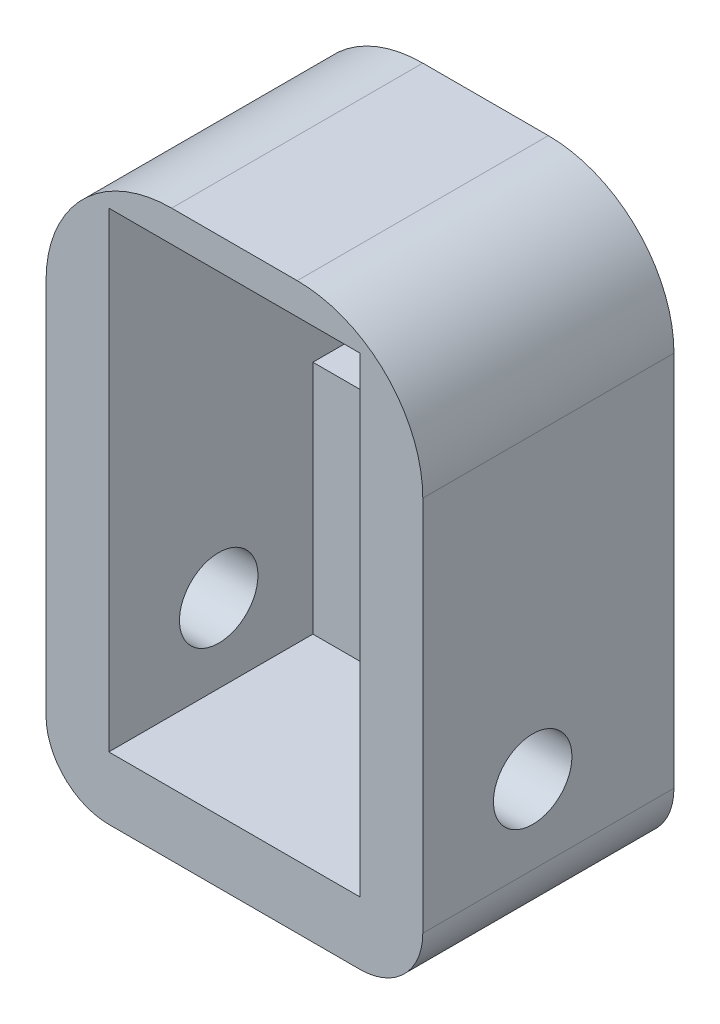
from build123d import *

# Parameters (mm, degrees)
SKETCH_1_W         = 12
SKETCH_1_H         = 18
SKETCH_1_W_2       = 8
SKETCH_1_H_2       = 15
EXTRUDE_1_DEPTH    = 8
SKETCH_1_3_W       = 8
SKETCH_1_3_H       = 7.5
EXTRUDE_2_DEPTH    = 1.5
HOLE_WIZARD_M3_1_D = 2.5
FILLET_2_R         = 4
FILLET_3_R         = 2


with BuildPart() as part:
    # 草图1 → 凸台-拉伸1 (new body)
    with BuildSketch(Plane.XY):
        with Locations((4, 7)):
            Rectangle(SKETCH_1_W, SKETCH_1_H)
        with Locations((4, 7.5)):
            Rectangle(SKETCH_1_W_2, SKETCH_1_H_2, mode=Mode.SUBTRACT)
    extrude(amount=EXTRUDE_1_DEPTH)

    # 草图1<3> → 凸台-拉伸2 (add)
    with BuildSketch(Plane.XY):
        with Locations((4, 3.75)):
            Rectangle(SKETCH_1_3_W, SKETCH_1_3_H)
    extrude(amount=EXTRUDE_2_DEPTH)

    # M3 螺纹孔1 (through all)
    with Locations(Plane(origin=(10, 0, 0), x_dir=(0, 0, -1), z_dir=(1, 0, 0))):
        with Locations((-4.5, 2.5)):
            Hole(HOLE_WIZARD_M3_1_D / 2)

    # 圆角2
    fillet_2_edges = [part.edges().sort_by_distance(p)[0] for p in [
        (10, 16, 4),
        (-2, 16, 4),
    ]]
    fillet(fillet_2_edges, radius=FILLET_2_R)

    # 圆角3
    fillet_3_edges = [part.edges().sort_by_distance(p)[0] for p in [
        (10, -2, 4),
        (-2, -2, 4),
    ]]
    fillet(fillet_3_edges, radius=FILLET_3_R)


solid = part.part
